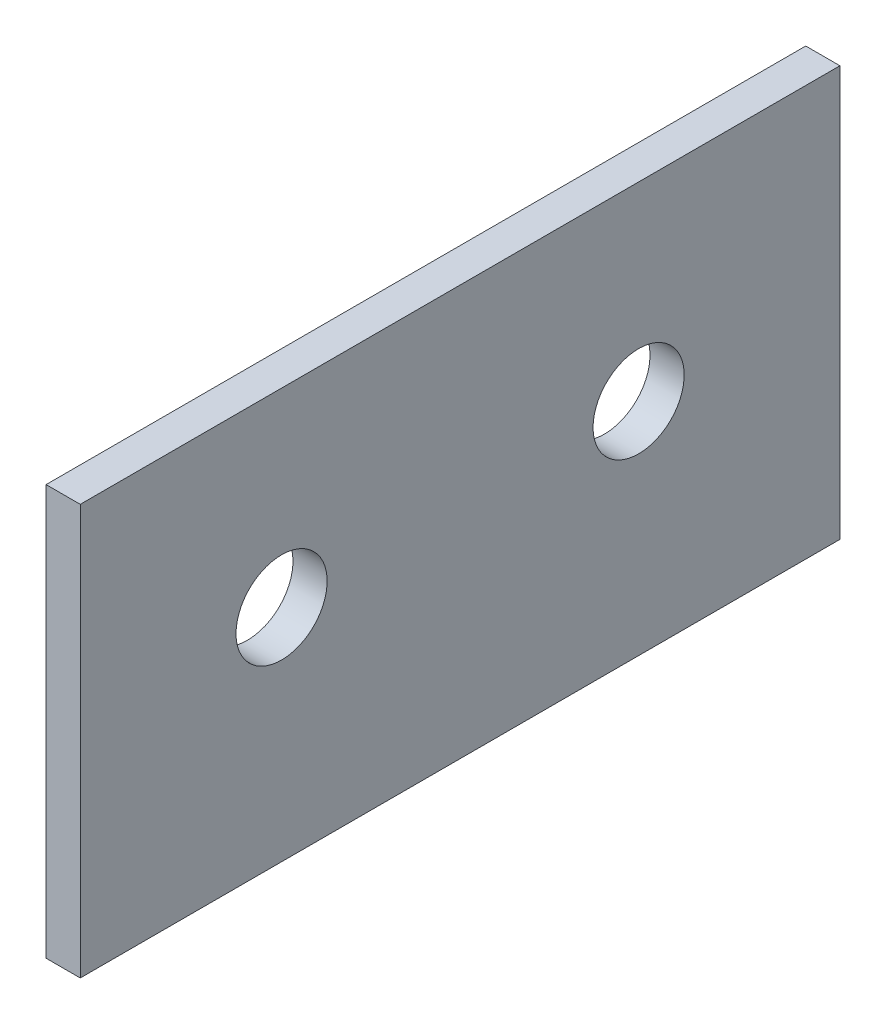
from build123d import *

# Parameters (mm, degrees)
EKSTR_ZYON_NCE1_DEPTH = 50
IZIM2_R               = 3
KES_EKSTR_ZYON1_DEPTH = 78
IZIM3_R               = 0.5
KES_EKSTR_ZYON2_DEPTH = 22
IZIM4_R               = 6
KES_EKSTR_ZYON3_DEPTH = 22
SCALE1_SCALE          = 0.666666667
SKETCH3_W             = 33.333333334
SKETCH3_H             = 19.333333333
CUT_EXTRUDE1_DEPTH    = 2
SKETCH4_W             = 56
SKETCH4_H             = 55
BOSS_EXTRUDE1_DEPTH   = 2
SKETCH5_W             = 33.333333334
SKETCH5_H             = 18
BOSS_EXTRUDE2_DEPTH   = 1.5
SKETCH6_R             = 2
CUT_EXTRUDE2_DEPTH    = 1.5
SKETCH7_W             = 56.964320229
SKETCH7_H             = 23.03419096
CUT_EXTRUDE5_DEPTH    = 56
SKETCH8_W             = 56.142360806
SKETCH8_H             = 4.377004861
CUT_EXTRUDE6_DEPTH    = 2.5


with BuildPart() as part:
    # Çizim1 → Ekstrüzyon-İnce1 (new body)
    with BuildSketch(Plane.XY):
        with BuildLine():
            Line((0, 0), (0, 29))
            ThreePointArc((0, 29), (0.292893219, 29.707106781), (1, 30))
            Line((1, 30), (57, 30))
            ThreePointArc((57, 30), (57.707106781, 29.707106781), (58, 29))
            Line((58, 29), (58, 0))
            Line((58, 0), (57, 0))
            Line((57, 0), (57, 29))
            Line((57, 29), (1, 29))
            Line((1, 29), (1, 0))
            Line((1, 0), (0, 0))
        make_face()
    extrude(amount=EKSTR_ZYON_NCE1_DEPTH)

    # Çizim2 → Kes-Ekstrüzyon1 (cut)
    with BuildSketch(Plane(origin=(58, 0, 0), x_dir=(0, 0, -1), z_dir=(1, 0, 0))):
        with Locations((-36.75, 14.5)):
            Circle(IZIM2_R)
        with Locations((-13.25, 14.5)):
            Circle(IZIM2_R)
    extrude(amount=-KES_EKSTR_ZYON1_DEPTH, mode=Mode.SUBTRACT)

    # Çizim3 → Kes-Ekstrüzyon2 (cut)
    with BuildSketch(Plane.ZY):
        with Locations((46.926319902, 2.636193895)):
            Circle(IZIM3_R)
    extrude(amount=-KES_EKSTR_ZYON2_DEPTH, mode=Mode.SUBTRACT)

    # Çizim4 → Kes-Ekstrüzyon3 (cut)
    with BuildSketch(Plane.ZY):
        with Locations((36.75, 14.5)):
            Circle(IZIM4_R)
    extrude(amount=-KES_EKSTR_ZYON3_DEPTH, mode=Mode.SUBTRACT)


with BuildPart() as part_1:
    # Scale1: scaled about (29.437260205, 22.238846327, 24.818293672)
    add(part.part.scale(SCALE1_SCALE).moved(Location((9.812420068, 7.412948776, 8.272764557))))

    # Sketch3 → Cut-Extrude1 (cut)
    with BuildSketch(Plane(origin=(48.479086735, 0, 0), x_dir=(0, 0, -1), z_dir=(1, 0, 0))):
        with Locations((-24.939431224, 17.079615442)):
            Rectangle(SKETCH3_W, SKETCH3_H)
    extrude(amount=-CUT_EXTRUDE1_DEPTH, mode=Mode.SUBTRACT)

    # Sketch4 → Boss-Extrude1 (add)
    with BuildSketch(Plane(origin=(0, 27.412948776, 0), x_dir=(1, 0, 0), z_dir=(0, 1, 0))):
        with Locations((38.479086736, -24.938368242)):
            Rectangle(SKETCH4_W, SKETCH4_H)
    extrude(amount=-BOSS_EXTRUDE1_DEPTH)

    # Sketch5 → Boss-Extrude2 (add)
    with BuildSketch(Plane(origin=(66.479086736, 0, 0), x_dir=(0, 0, -1), z_dir=(1, 0, 0))):
        with Locations((-24.939431224, 16.412948776)):
            Rectangle(SKETCH5_W, SKETCH5_H)
    extrude(amount=-BOSS_EXTRUDE2_DEPTH)

    # Sketch6 → Cut-Extrude2 (cut)
    with BuildSketch(Plane.ZY.offset(-64.979086736)):
        with Locations((17.106097891, 17.079615442)):
            Circle(SKETCH6_R)
        with Locations((32.772764557, 17.079615442)):
            Circle(SKETCH6_R)
    extrude(amount=-CUT_EXTRUDE2_DEPTH, mode=Mode.SUBTRACT)

    # Sketch7 → Cut-Extrude5 (cut, through all)
    with BuildSketch(Plane(origin=(0, 0, -2.561631758), x_dir=(-1, 0, 0), z_dir=(0, 0, -1))):
        with Locations((-36.496926622, 18.930044256)):
            Rectangle(SKETCH7_W, SKETCH7_H)
    extrude(amount=-CUT_EXTRUDE5_DEPTH, mode=Mode.SUBTRACT)

    # Sketch8 → Cut-Extrude6 (cut, through all)
    with BuildSketch(Plane.ZY.offset(-64.979086736)):
        with Locations((24.367187839, 27.601451207)):
            Rectangle(SKETCH8_W, SKETCH8_H)
    extrude(amount=-CUT_EXTRUDE6_DEPTH, mode=Mode.SUBTRACT)


solid = part_1.part
